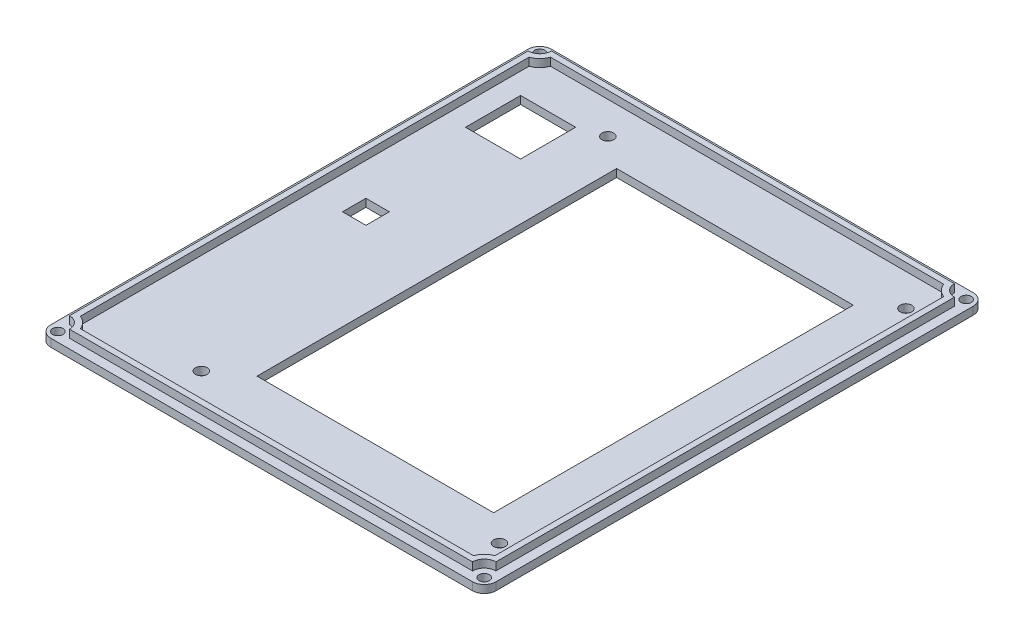
from build123d import *

# Parameters (mm, degrees)
SKETCH20_W            = 96.52
SKETCH20_H            = 108.5559932
BOSS_EXTRUDE5_DEPTH   = 1.699999902
BOSS_EXTRUDE6_DEPTH   = 1.7
FILLET3_R             = 2.54
F_4_40_TAPPED_HOLE3_D = 2.2606
SKETCH28_W            = 51.308
SKETCH28_H            = 77.978
SKETCH28_W_2          = 11.938
SKETCH28_H_2          = 11.938
SKETCH28_W_3          = 5.08
SKETCH28_H_3          = 5.08
SKETCH28_R            = 1.27
CUT_EXTRUDE1_DEPTH    = 8.89


with BuildPart() as part:
    # Sketch20 → Boss-Extrude5 (new body)
    with BuildSketch(Plane(origin=(0, 0, 0), x_dir=(1, 0, 0), z_dir=(0, 1, 0))):
        with Locations((46.26, 74.0579966)):
            Rectangle(SKETCH20_W, SKETCH20_H)
    extrude(amount=-BOSS_EXTRUDE5_DEPTH)

    # Sketch20_3 → Boss-Extrude6 (add)
    with BuildSketch(Plane(origin=(0, 0, 0), x_dir=(1, 0, 0), z_dir=(0, 1, 0))):
        with BuildLine():
            Line((2.572, 21.812), (89.948, 21.812))
            ThreePointArc((89.948, 21.812), (90.691948776, 23.608051224), (92.488, 24.352))
            Line((92.488, 24.352), (92.488, 123.7639932))
            ThreePointArc((92.488, 123.7639932), (90.691948776, 124.507941976), (89.948, 126.3039932))
            Line((89.948, 126.3039932), (2.572, 126.3039932))
            ThreePointArc((2.572, 126.3039932), (1.828051224, 124.507941976), (0.032, 123.7639932))
            Line((0.032, 123.7639932), (0.032, 24.352))
            ThreePointArc((0.032, 24.352), (1.828051224, 23.608051224), (2.572, 21.812))
        make_face()
        with BuildLine():
            Line((3.624102448, 23.082), (88.895897552, 23.082))
            ThreePointArc((88.895897552, 23.082), (89.793923164, 24.506076836), (91.218, 25.404102448))
            Line((91.218, 25.404102448), (91.218, 122.711890752))
            ThreePointArc((91.218, 122.711890752), (89.793923164, 123.609916364), (88.895897552, 125.0339932))
            Line((88.895897552, 125.0339932), (3.624102448, 125.0339932))
            ThreePointArc((3.624102448, 125.0339932), (2.726076836, 123.609916364), (1.302, 122.711890752))
            Line((1.302, 122.711890752), (1.302, 25.404102448))
            ThreePointArc((1.302, 25.404102448), (2.726076836, 24.506076836), (3.624102448, 23.082))
        make_face(mode=Mode.SUBTRACT)
    extrude(amount=BOSS_EXTRUDE6_DEPTH)

    # Fillet3
    fillet3_edges = [part.edges().sort_by_distance(p)[0] for p in [
        (-2, -0.849999951, -19.78),
        (-2, -0.849999951, -128.3359932),
        (94.52, -0.849999951, -128.3359932),
        (94.52, -0.849999951, -19.78),
    ]]
    fillet(fillet3_edges, radius=FILLET3_R)

    # 4-40 Tapped Hole3 (through all)
    with Locations(Plane(origin=(0, 0, 0), x_dir=(1, 0, 0), z_dir=(0, 1, 0))):
        with Locations((0.032, 21.812), (92.488, 21.812), (92.488, 126.3039932), (0.032, 126.3039932)):
            Hole(F_4_40_TAPPED_HOLE3_D / 2)

    # Sketch28 → Cut-Extrude1 (cut)
    with BuildSketch(Plane.XZ.offset(1.699999902)):
        with Locations((55.658, -74.009)):
            Rectangle(SKETCH28_W, SKETCH28_H)
        with Locations((11.843, -110.331)):
            Rectangle(SKETCH28_W_2, SKETCH28_H_2)
        with Locations((10.954, -77.692)):
            Rectangle(SKETCH28_W_3, SKETCH28_H_3)
        with Locations((87.662, -29.94)):
            Circle(SKETCH28_R)
        with Locations((87.662, -118.078)):
            Circle(SKETCH28_R)
        with Locations((23.019, -29.94)):
            Circle(SKETCH28_R)
        with Locations((23.019, -118.078)):
            Circle(SKETCH28_R)
    extrude(amount=-CUT_EXTRUDE1_DEPTH, mode=Mode.SUBTRACT)


solid = part.part
